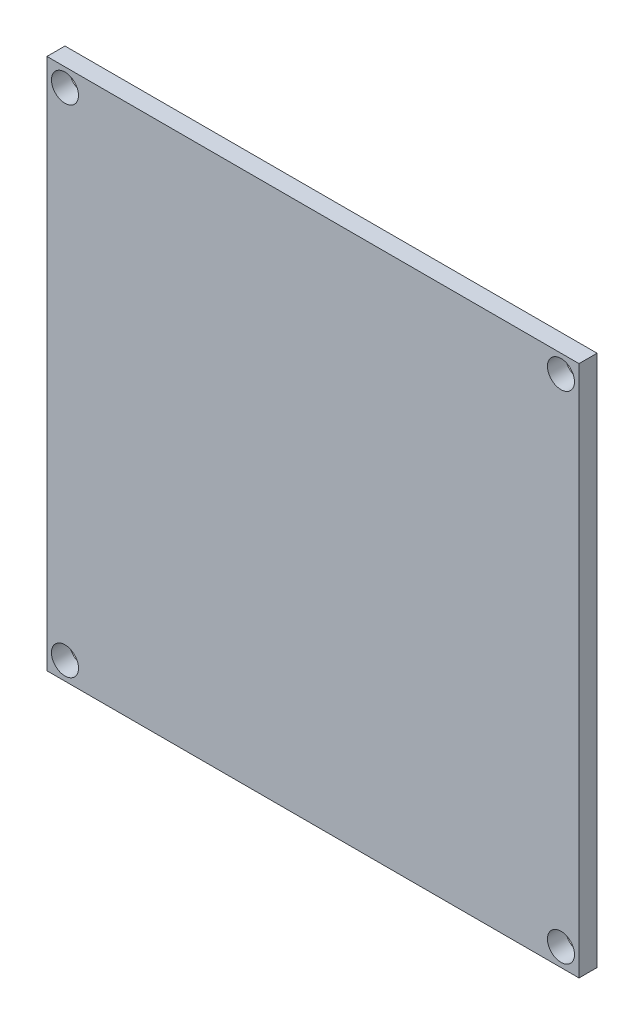
from build123d import *

# Parameters (mm, degrees)
CROQUIS1_W              = 59
CROQUIS1_H              = 59
CROQUIS1_R              = 1.5
SALIENTE_EXTRUIR3_DEPTH = 2


with BuildPart() as part:
    # Croquis1 → Saliente-Extruir3 (new body)
    with BuildSketch(Plane.XY):
        with Locations((-59.641884519, 0.988826816)):
            Rectangle(CROQUIS1_W, CROQUIS1_H)
        with Locations((-87.141884519, 28.488826816)):
            Circle(CROQUIS1_R, mode=Mode.SUBTRACT)
        with Locations((-32.141884519, 28.488826816)):
            Circle(CROQUIS1_R, mode=Mode.SUBTRACT)
        with Locations((-32.141884519, -26.511173184)):
            Circle(CROQUIS1_R, mode=Mode.SUBTRACT)
        with Locations((-87.141884519, -26.511173184)):
            Circle(CROQUIS1_R, mode=Mode.SUBTRACT)
    extrude(amount=SALIENTE_EXTRUIR3_DEPTH)


solid = part.part
